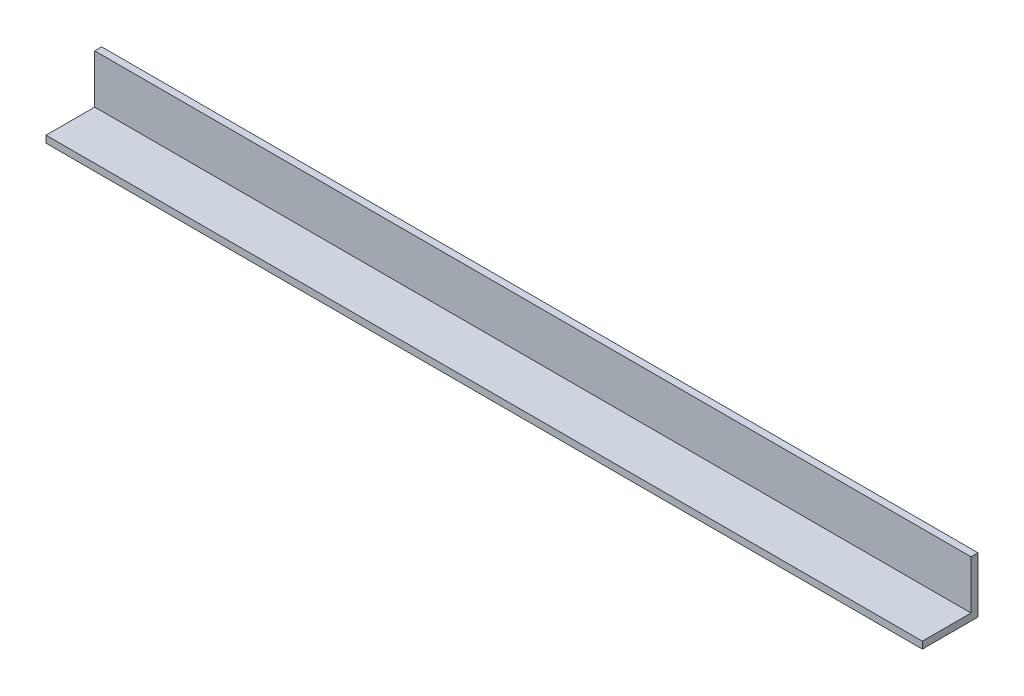
from build123d import *

# Parameters (mm, degrees)
SALIENTE_EXTRUIR1_DEPTH = 400


with BuildPart() as part:
    # Croquis1 → Saliente-Extruir1 (new body)
    with BuildSketch(Plane(origin=(0, 0, 0), x_dir=(0, 0, -1), z_dir=(1, 0, 0))):
        Polygon((0, 25.4), (0, 0), (-25.4, 0), (-25.4, 3.175), (-3.175, 3.175), (-3.175, 25.4), align=None)
    extrude(amount=SALIENTE_EXTRUIR1_DEPTH)


solid = part.part
